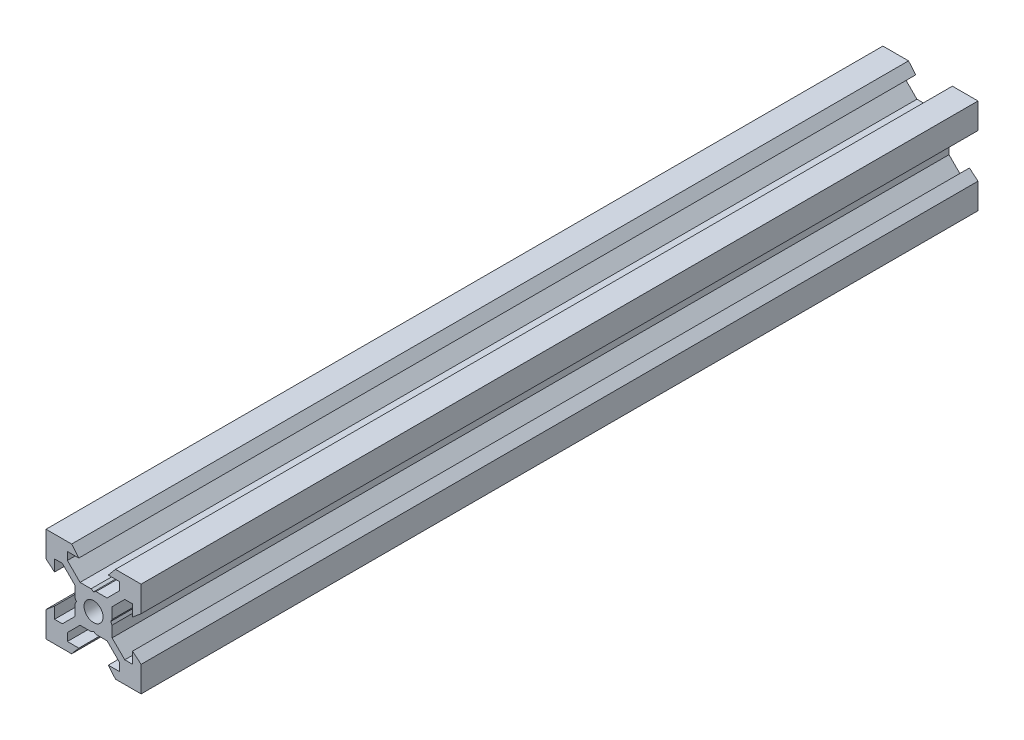
from build123d import *

# Parameters (mm, degrees)
SKETCH1_R           = 2
BOSS_EXTRUDE1_DEPTH = 88


with BuildPart() as part:
    # Sketch1 → Boss-Extrude1 (new body, symmetric)
    with BuildSketch(Plane.XY):
        Polygon((10, 10), (10, 4.610379336), (8.2, 3.1), (8.2, 5.5), (6.560660172, 5.5), (3.9, 2.839339828), (3.9, 0.519615242), (3.6, 0), (3.9, -0.519615242), (3.9, -2.839339828), (6.560660172, -5.5), (8.2, -5.5), (8.2, -3.1), (10, -4.610379336), (10, -10), (4.610379336, -10), (3.1, -8.2), (5.5, -8.2), (5.5, -6.560660172), (2.839339828, -3.9), (0.519615242, -3.9), (0, -3.6), (-0.519615242, -3.9), (-2.839339828, -3.9), (-5.5, -6.560660172), (-5.5, -8.2), (-3.1, -8.2), (-4.610379336, -10), (-10, -10), (-10, -4.610379336), (-8.2, -3.1), (-8.2, -5.5), (-6.560660172, -5.5), (-3.9, -2.839339828), (-3.9, -0.519615242), (-3.6, 0), (-3.9, 0.519615242), (-3.9, 2.839339828), (-6.560660172, 5.5), (-8.2, 5.5), (-8.2, 3.1), (-10, 4.610379336), (-10, 10), (-4.610379336, 10), (-3.1, 8.2), (-5.5, 8.2), (-5.5, 6.560660172), (-2.839339828, 3.9), (-0.519615242, 3.9), (0, 3.6), (0.519615242, 3.9), (2.839339828, 3.9), (5.5, 6.560660172), (5.5, 8.2), (3.1, 8.2), (4.610379336, 10), align=None)
        Circle(SKETCH1_R, mode=Mode.SUBTRACT)
    extrude(amount=BOSS_EXTRUDE1_DEPTH, both=True)


solid = part.part
